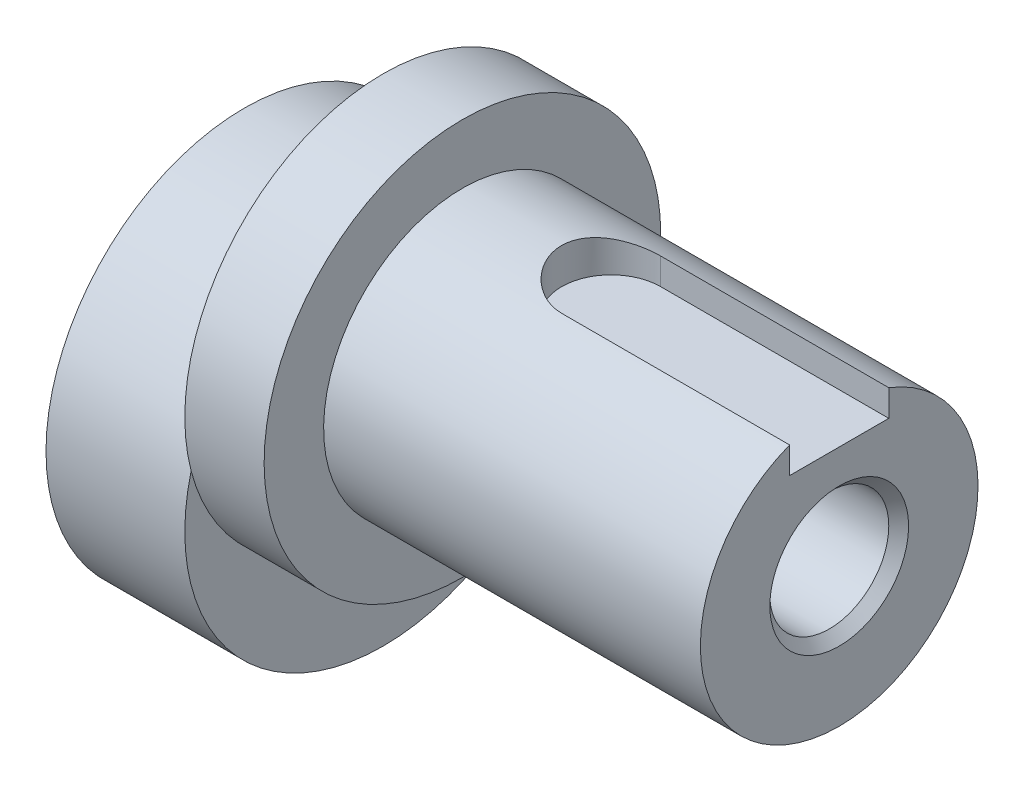
from build123d import *

# Parameters (mm, degrees)
SKETCH1_R           = 10
BOSS_EXTRUDE1_DEPTH = 7
SKETCH2_R           = 10
BOSS_EXTRUDE2_DEPTH = 4
SKETCH3_R           = 7
BOSS_EXTRUDE3_DEPTH = 19
SKETCH4_R           = 3
CUT_EXTRUDE1_DEPTH  = 31
CHAMFER1_SIZE       = 0.5
CUT_EXTRUDE2_START  = 10.2
CUT_EXTRUDE2_DEPTH  = 5.8


with BuildPart() as part:
    # Sketch1 → Boss-Extrude1 (new body)
    with BuildSketch(Plane(origin=(0, 0, 0), x_dir=(0, 0, -1), z_dir=(1, 0, 0))):
        Circle(SKETCH1_R)
    extrude(amount=BOSS_EXTRUDE1_DEPTH)

    # Sketch2 → Boss-Extrude2 (add)
    with BuildSketch(Plane(origin=(7, 0, 0), x_dir=(0, 0, -1), z_dir=(1, 0, 0))):
        with Locations((0, 5)):
            Circle(SKETCH2_R)
    extrude(amount=BOSS_EXTRUDE2_DEPTH)

    # Sketch3 → Boss-Extrude3 (add)
    with BuildSketch(Plane(origin=(11, 0, 0), x_dir=(0, 0, -1), z_dir=(1, 0, 0))):
        with Locations((0, 5)):
            Circle(SKETCH3_R)
    extrude(amount=BOSS_EXTRUDE3_DEPTH)

    # Sketch4 → Cut-Extrude1 (cut, through all)
    with BuildSketch(Plane(origin=(30, 0, 0), x_dir=(0, 0, -1), z_dir=(1, 0, 0))):
        with Locations((0, 5)):
            Circle(SKETCH4_R)
    extrude(amount=-CUT_EXTRUDE1_DEPTH, mode=Mode.SUBTRACT)

    # Chamfer1
    chamfer1_edges = [part.edges().sort_by_distance(p)[0] for p in [
        (0, 5, 3),
        (30, 5, 3),
    ]]
    chamfer(chamfer1_edges, length=CHAMFER1_SIZE)

    # Sketch5 → Cut-Extrude2 (cut, through all)
    with BuildSketch(Plane(origin=(0, 0, 0), x_dir=(1, 0, 0), z_dir=(0, 1, 0)).offset(CUT_EXTRUDE2_START)):
        with BuildLine():
            Line((31, 2.5), (18.5, 2.5))
            ThreePointArc((18.5, 2.5), (16, 0), (18.5, -2.5))
            Line((18.5, -2.5), (31, -2.5))
            Line((31, -2.5), (31, 2.5))
        make_face()
    extrude(amount=CUT_EXTRUDE2_DEPTH, mode=Mode.SUBTRACT)


solid = part.part
